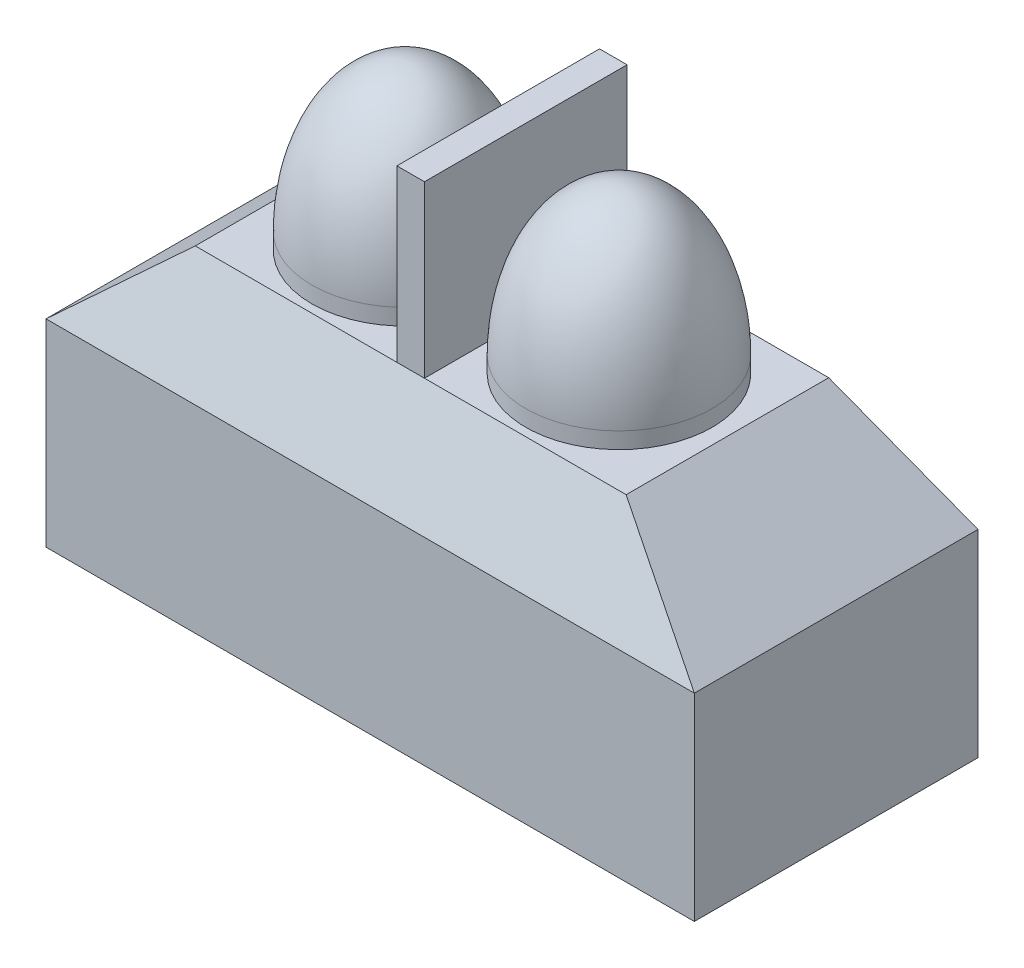
from build123d import *

# Parameters (mm, degrees)
SKETCH1_W             = 10.16
SKETCH1_H             = 4.445
BOSS_EXTRUDE1_DEPTH   = 3.0988
SKETCH3_W             = 10.16
SKETCH3_H             = 4.445
BOSS_EXTRUDE3_DEPTH   = 1.524
CUT_EXTRUDE1_DEPTH    = 9.181363263
CUT_EXTRUDE3_DEPTH    = 12.381361346
SKETCH9_W             = 0.4318
SKETCH9_H             = 3.175
BOSS_EXTRUDE4_DEPTH   = 2.667
SKETCH10_R            = 1.4605
BOSS_EXTRUDE6_DEPTH   = 0.254
BOSS_EXTRUDE6_2_DEPTH = 0.254
DOME2_FACE_RADIUS     = 1.4605
DOME2_HEIGHT          = 2.286
DOME3_FACE_RADIUS     = 1.4605
DOME3_HEIGHT          = 2.286


with BuildPart() as part:
    # Sketch1 → Boss-Extrude1 (new body)
    with BuildSketch(Plane(origin=(0, 0, 0), x_dir=(1, 0, 0), z_dir=(0, 1, 0))):
        Rectangle(SKETCH1_W, SKETCH1_H)
    extrude(amount=BOSS_EXTRUDE1_DEPTH)

    # Sketch3 → Boss-Extrude3 (add)
    with BuildSketch(Plane(origin=(0, 3.0988, 0), x_dir=(-1, 0, 0), z_dir=(0, 1, 0))):
        Rectangle(SKETCH3_W, SKETCH3_H)
    extrude(amount=BOSS_EXTRUDE3_DEPTH)

    # Sketch4 → Cut-Extrude1 (cut, through all)
    with BuildSketch(Plane(origin=(0, 0, -2.2225), x_dir=(-1, 0, 0), z_dir=(0, 0, -1))):
        Polygon((-3.376116201, 4.6228), (-5.08, 3.0988), (-5.08, 4.6228), align=None)
        Polygon((5.08, 4.6228), (3.376116201, 4.6228), (5.08, 3.0988), align=None)
    extrude(amount=-CUT_EXTRUDE1_DEPTH, mode=Mode.SUBTRACT)

    # Sketch8 → Cut-Extrude3 (cut, through all)
    with BuildSketch(Plane(origin=(5.08, 0, 0), x_dir=(0, 0, -1), z_dir=(1, 0, 0))):
        Polygon((2.2225, 4.6228), (1.5875, 4.6228), (2.2225, 3.0988), align=None)
        Polygon((-2.2225, 4.6228), (-2.2225, 3.0988), (-1.5875, 4.6228), align=None)
    extrude(amount=-CUT_EXTRUDE3_DEPTH, mode=Mode.SUBTRACT)

    # Sketch9 → Boss-Extrude4 (add)
    with BuildSketch(Plane(origin=(0, 4.6228, 0), x_dir=(-1, 0, 0), z_dir=(0, 1, 0))):
        Rectangle(SKETCH9_W, SKETCH9_H)
    extrude(amount=BOSS_EXTRUDE4_DEPTH)


with BuildPart() as body_2:
    # Sketch10 → Boss-Extrude6 (new body)
    with BuildSketch(Plane(origin=(0, 4.6228, 0), x_dir=(1, 0, 0), z_dir=(0, 1, 0))):
        with Locations((-1.6764, 0)):
            Circle(SKETCH10_R)
    extrude(amount=BOSS_EXTRUDE6_DEPTH)

    # Dome2: an elliptical dome of height H over a round flat face of radius A is half a spheroid: the quarter ellipse of half axes A and H revolved about the face's axis
    with BuildSketch(Plane((-1.6764, 4.8768, 0), x_dir=(0, 0, -1), z_dir=(1, 0, 0)), mode=Mode.PRIVATE) as dome2_quarter:
        Ellipse(DOME2_FACE_RADIUS, DOME2_HEIGHT)
        Rectangle(DOME2_FACE_RADIUS, DOME2_HEIGHT, align=(Align.MIN, Align.MIN), mode=Mode.INTERSECT)
    revolve(dome2_quarter.sketch, axis=Axis((-1.6764, 4.8768, 0), (0, 1, 0)))


with BuildPart() as body_3:
    # Sketch10 → Boss-Extrude6 2 (new body)
    with BuildSketch(Plane(origin=(0, 4.6228, 0), x_dir=(1, 0, 0), z_dir=(0, 1, 0))):
        with Locations((1.6764, 0)):
            Circle(SKETCH10_R)
    extrude(amount=BOSS_EXTRUDE6_2_DEPTH)

    # Dome3: an elliptical dome of height H over a round flat face of radius A is half a spheroid: the quarter ellipse of half axes A and H revolved about the face's axis
    with BuildSketch(Plane((1.6764, 4.8768, 0), x_dir=(0, 0, -1), z_dir=(1, 0, 0)), mode=Mode.PRIVATE) as dome3_quarter:
        Ellipse(DOME3_FACE_RADIUS, DOME3_HEIGHT)
        Rectangle(DOME3_FACE_RADIUS, DOME3_HEIGHT, align=(Align.MIN, Align.MIN), mode=Mode.INTERSECT)
    revolve(dome3_quarter.sketch, axis=Axis((1.6764, 4.8768, 0), (0, 1, 0)))


solid = Compound([part.part, body_2.part, body_3.part])
